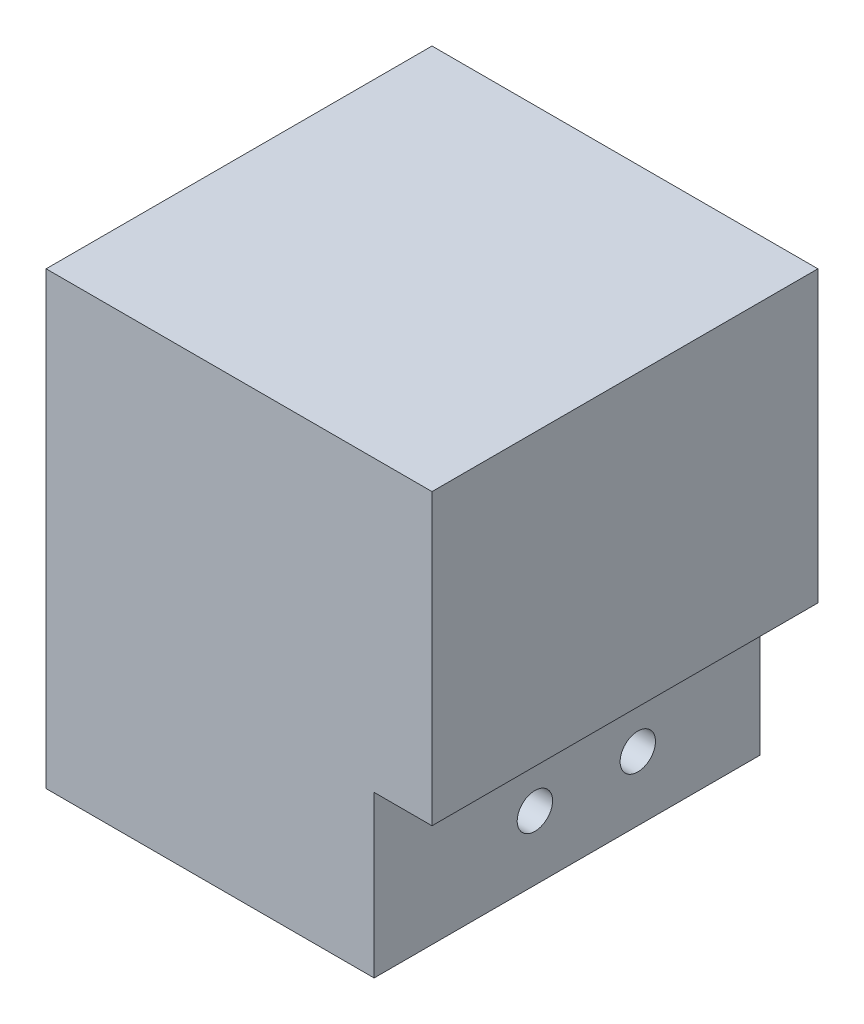
from build123d import *

# Parameters (mm, degrees)
SKETCH1_W            = 60
SKETCH1_H            = 70
BOSS_EXTRUDE1_DEPTH  = 60
SKETCH2_W            = 60
SKETCH2_H            = 25
CUT_EXTRUDE1_DEPTH   = 9
M5_CLEARANCE_HOLE1_D = 5.5
SKETCH12_R           = 6.75
CUT_EXTRUDE2_DEPTH   = 25


with BuildPart() as part:
    # Sketch1 → Boss-Extrude1 (new body)
    with BuildSketch(Plane.XY):
        with Locations((-30, 35)):
            Rectangle(SKETCH1_W, SKETCH1_H)
    extrude(amount=BOSS_EXTRUDE1_DEPTH)

    # Sketch2 → Cut-Extrude1 (cut)
    with BuildSketch(Plane(origin=(0, 0, 0), x_dir=(0, 0, -1), z_dir=(1, 0, 0))):
        with Locations((-30, 12.5)):
            Rectangle(SKETCH2_W, SKETCH2_H)
    extrude(amount=-CUT_EXTRUDE1_DEPTH, mode=Mode.SUBTRACT)

    # M5 Clearance Hole1 (through all)
    with Locations(Plane(origin=(-9, 10, 35), x_dir=(0, 0, 1), z_dir=(1, 0, 0))):
        with Locations((0, 0), (-16, 0)):
            Hole(M5_CLEARANCE_HOLE1_D / 2)

    # Sketch12 → Cut-Extrude2 (cut)
    with BuildSketch(Plane.ZY.offset(60)):
        with Locations((19, 10)):
            Circle(SKETCH12_R)
        with Locations((35, 10)):
            Circle(SKETCH12_R)
    extrude(amount=-CUT_EXTRUDE2_DEPTH, mode=Mode.SUBTRACT)


solid = part.part
